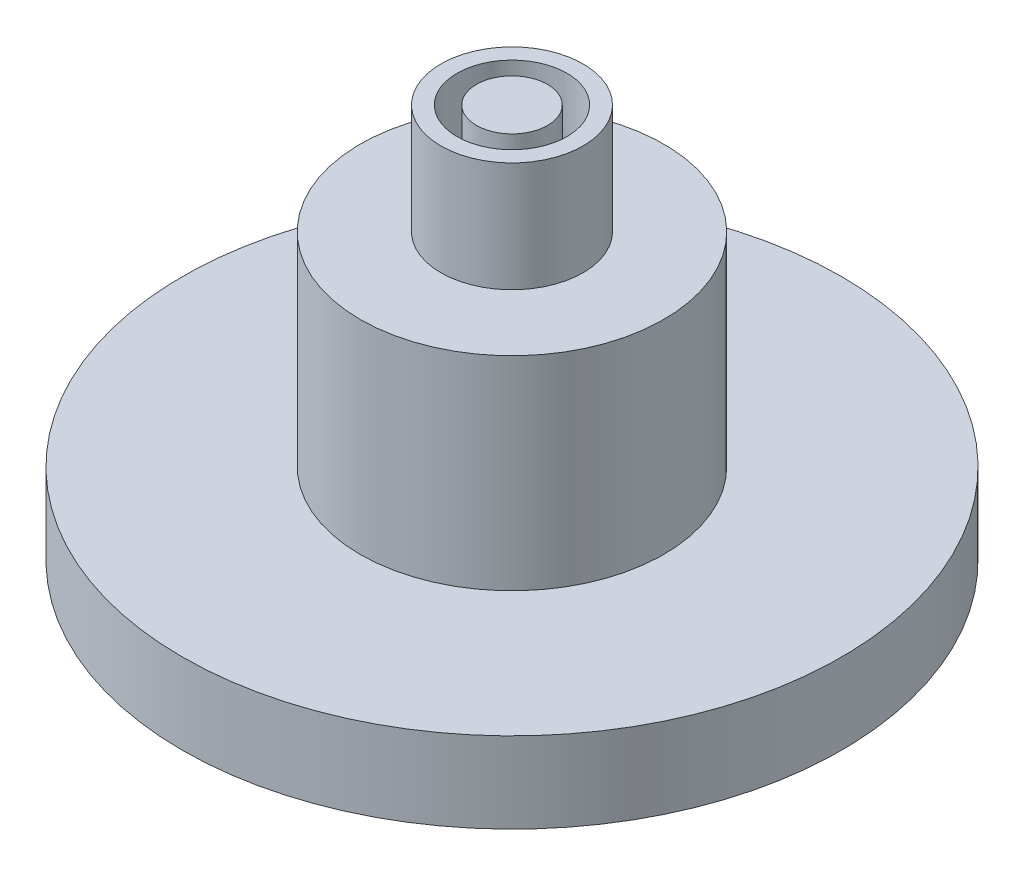
from build123d import *

# Parameters (mm, degrees)
SKETCH2_R           = 12.954
BOSS_EXTRUDE1_DEPTH = 3.175
SKETCH3_R           = 5.969
BOSS_EXTRUDE2_DEPTH = 8.001
SKETCH4_R           = 2.794
SKETCH4_R_2         = 2.159
SKETCH4_R_3         = 1.397
BOSS_EXTRUDE3_DEPTH = 4.318


with BuildPart() as part:
    # Sketch2 → Boss-Extrude1 (new body)
    with BuildSketch(Plane(origin=(0, 0, 0), x_dir=(1, 0, 0), z_dir=(0, 1, 0))):
        with Locations(Location((0, 0, 0), (0, 0, 270))):
            Circle(SKETCH2_R)
    extrude(amount=BOSS_EXTRUDE1_DEPTH)

    # Sketch3 → Boss-Extrude2 (add)
    with BuildSketch(Plane(origin=(0, 3.175, 0), x_dir=(1, 0, 0), z_dir=(0, 1, 0))):
        with Locations(Location((0, 0, 0), (0, 0, 270))):
            Circle(SKETCH3_R)
    extrude(amount=BOSS_EXTRUDE2_DEPTH)

    # Sketch4 → Boss-Extrude3 (add)
    with BuildSketch(Plane(origin=(0, 11.176, 0), x_dir=(1, 0, 0), z_dir=(0, 1, 0))):
        with Locations(Location((0, 0, 0), (0, 0, 270))):
            Circle(SKETCH4_R)
        with Locations(Location((0, 0, 0), (0, 0, 270))):
            Circle(SKETCH4_R_2, mode=Mode.SUBTRACT)
        with Locations(Location((0, 0, 0), (0, 0, 270))):
            Circle(SKETCH4_R_3)
    extrude(amount=BOSS_EXTRUDE3_DEPTH)


solid = part.part
